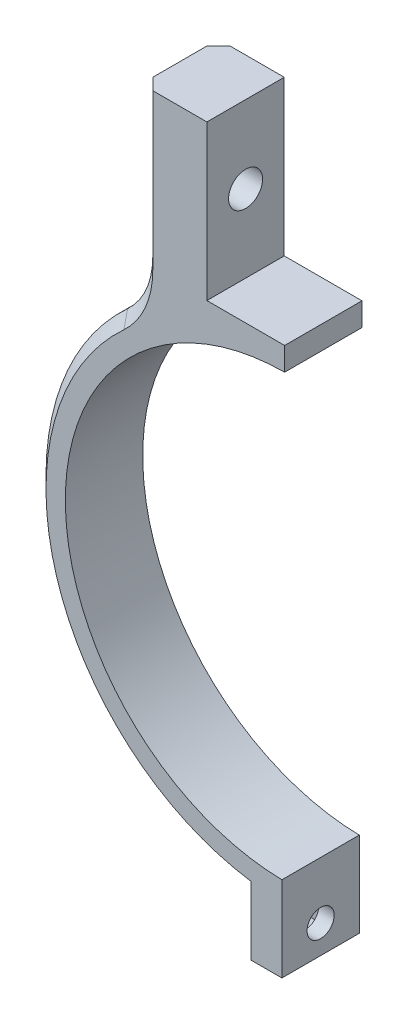
from build123d import *

# Parameters (mm, degrees)
AUFSATZ_LINEAR_AUSTRAGEN1_DEPTH = 10
SKIZZE2_R                       = 1.75
SCHNITT_LINEAR_AUSTRAGEN1_DEPTH = 38
SKIZZE4_R                       = 2.2
SCHNITT_LINEAR_AUSTRAGEN3_DEPTH = 52.2
VERRUNDUNG1_R                   = 10
SKIZZE5_W                       = 5.5
SKIZZE5_H                       = 5.5
SCHNITT_LINEAR_AUSTRAGEN4_DEPTH = 2
FASE1_SIZE                      = 1.5
SCHNITT_LINEAR_AUSTRAGEN5_DEPTH = 11


with BuildPart() as part:
    # Skizze1 → Aufsatz-Linear austragen1 (new body)
    with BuildSketch(Plane.XY):
        with BuildLine():
            Line((0.5, -28.495613698), (0.5, -32.496153619))
            Line((0.5, -32.496153619), (0.5, -39.496153619))
            Line((0.5, -39.496153619), (4.5, -39.496153619))
            Line((4.5, -39.496153619), (4.5, -32.186953879))
            ThreePointArc((4.5, -32.186953879), (31.590882714, -7.633225356), (18.7, 26.581196361))
            Line((18.7, 26.581196361), (18.7, 51.5))
            Line((18.7, 51.5), (10.2, 51.5))
            Line((10.2, 51.5), (10.2, 31.5))
            Line((10.2, 31.5), (-10.2, 31.5))
            Line((-10.2, 31.5), (-10.2, 51.5))
            Line((-10.2, 51.5), (-18.7, 51.5))
            Line((-18.7, 51.5), (-18.7, 26.581196361))
            ThreePointArc((-18.7, 26.581196361), (-31.590882714, -7.633225356), (-4.5, -32.186953879))
            Line((-4.5, -32.186953879), (-4.5, -39.496153619))
            Line((-4.5, -39.496153619), (-0.5, -39.496153619))
            Line((-0.5, -39.496153619), (-0.5, -32.496153619))
            Line((-0.5, -32.496153619), (-0.5, -28.495613698))
            ThreePointArc((-0.5, -28.495613698), (0, 28.5), (0.5, -28.495613698))
        make_face()
    extrude(amount=AUFSATZ_LINEAR_AUSTRAGEN1_DEPTH)

    # Skizze2 → Schnitt-Linear austragen1 (cut, through all)
    with BuildSketch(Plane.ZY.offset(4.5)):
        with Locations((5, -35.841553749)):
            Circle(SKIZZE2_R)
    extrude(amount=-SCHNITT_LINEAR_AUSTRAGEN1_DEPTH, mode=Mode.SUBTRACT)

    # Skizze4 → Schnitt-Linear austragen3 (cut, through all)
    with BuildSketch(Plane.ZY.offset(18.7)):
        with Locations((5, 41.5)):
            Circle(SKIZZE4_R)
    extrude(amount=-SCHNITT_LINEAR_AUSTRAGEN3_DEPTH, mode=Mode.SUBTRACT)

    # Verrundung1
    verrundung1_edges = [part.edges().sort_by_distance(p)[0] for p in [
        (-18.7, 26.581196361, 5),
        (18.7, 26.581196361, 5),
    ]]
    fillet(verrundung1_edges, radius=VERRUNDUNG1_R)

    # Skizze5 → Schnitt-Linear austragen4 (cut)
    with BuildSketch(Plane.ZY.offset(4.5)):
        with Locations((5, -35.841553749)):
            Rectangle(SKIZZE5_W, SKIZZE5_H)
    extrude(amount=-SCHNITT_LINEAR_AUSTRAGEN4_DEPTH, mode=Mode.SUBTRACT)

    # Fase1
    fase1_edges = [part.edges().sort_by_distance(p)[0] for p in [
        (-18.7, 41.422906559, 0),
        (31.036620275, -9.642520517, 0),
        (-18.7, 41.422906559, 10),
        (18.7, 41.422906559, 0),
        (18.7, 41.422906559, 10),
        (31.036620275, -9.642520517, 10),
        (-31.036620275, -9.642520517, 0),
        (-31.036620275, -9.642520517, 10),
        (19.547693958, 27.316508696, 0),
        (19.547693958, 27.316508696, 10),
        (-19.547693958, 27.316508696, 0),
        (-19.547693958, 27.316508696, 10),
    ]]
    chamfer(fase1_edges, length=FASE1_SIZE)

    # Skizze6 → Schnitt-Linear austragen5 (cut, through all)
    with BuildSketch(Plane.XY):
        Polygon((0, -80.065943577), (0, 27.478555263), (-0.15, 27.478555263), (-0.15, 32.428870792), (0, 32.428870792), (0, 80.065943577), (51.694887104, 80.065943577), (51.694887104, -72.979708266), align=None)
    extrude(amount=SCHNITT_LINEAR_AUSTRAGEN5_DEPTH, mode=Mode.SUBTRACT)


solid = part.part
